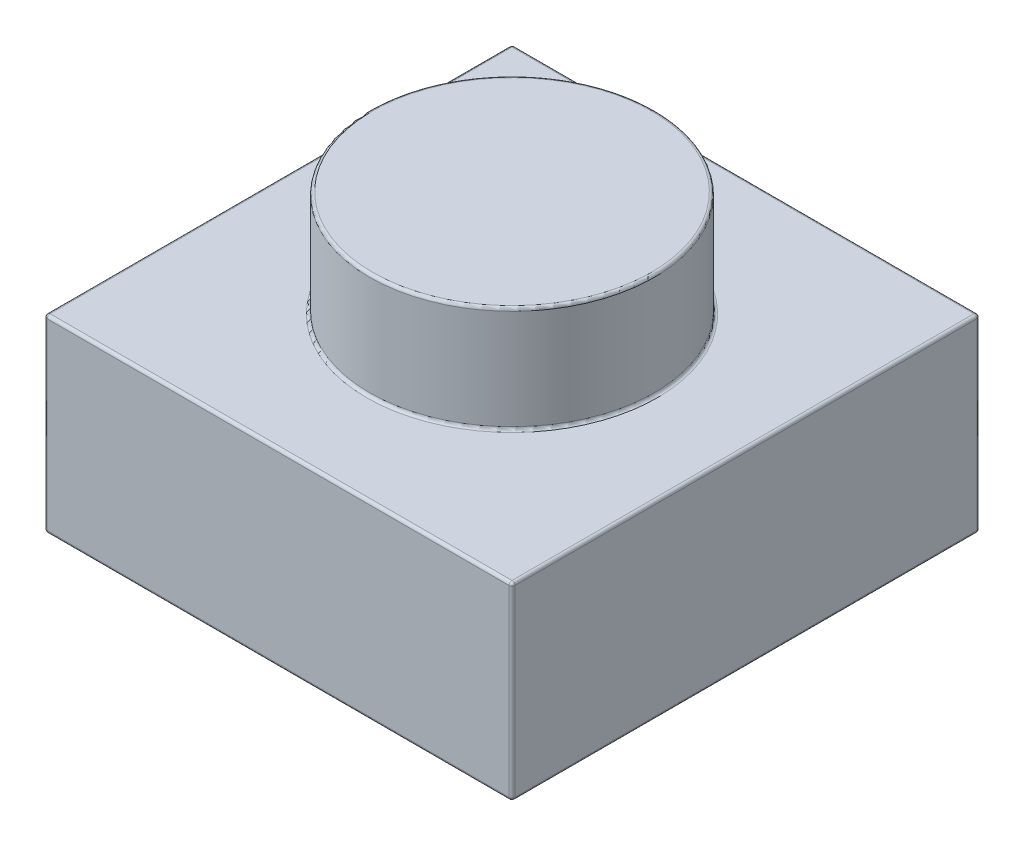
from build123d import *

# Parameters (mm, degrees)
SKETCH1_W      = 7.96
SKETCH1_H      = 7.96
EXTRUDE1_DEPTH = 3.22
SKETCH2_R      = 2.425
EXTRUDE2_DEPTH = 1.8
SHELL1_T       = -1.55
SKETCH3_W      = 4.86
SKETCH3_H      = 4.86
EXTRUDE3_DEPTH = 0.14
FILLET1_R      = 0.05


with BuildPart() as part:
    # Sketch1 → Extrude1 (new body)
    with BuildSketch(Plane(origin=(0, 0, 0), x_dir=(1, 0, 0), z_dir=(0, 1, 0))):
        Rectangle(SKETCH1_W, SKETCH1_H)
    extrude(amount=EXTRUDE1_DEPTH)

    # Sketch2 → Extrude2 (add)
    with BuildSketch(Plane(origin=(0, 3.22, 0), x_dir=(1, 0, 0), z_dir=(0, 1, 0))):
        Circle(SKETCH2_R)
    extrude(amount=EXTRUDE2_DEPTH)

    # Shell1
    shell1_openings = [part.faces().sort_by_distance(p)[0] for p in [
        (0, 0, 0),
    ]]
    offset(amount=SHELL1_T, openings=shell1_openings, kind=Kind.INTERSECTION)

    # Sketch3 → Extrude3 (cut)
    with BuildSketch(Plane.XZ.offset(-1.67)):
        Rectangle(SKETCH3_W, SKETCH3_H)
    extrude(amount=-EXTRUDE3_DEPTH, mode=Mode.SUBTRACT)

    # Fillet1
    fillet1_edges = [part.edges().sort_by_distance(p)[0] for p in [
        (-3.98, 3.22, 0),
        (0, 3.22, 3.98),
        (-2.425, 3.22, 0),
        (-2.425, 5.02, 0),
        (2.43, 0, 0),
        (2.43, 0.905, 2.43),
        (0, 0, -2.43),
        (2.43, 0.905, -2.43),
        (-2.43, 0, 0),
        (-2.43, 0.905, -2.43),
        (0, 0, 2.43),
        (-2.43, 0.905, 2.43),
        (-0.875, 3.47, 0),
        (-0.875, 1.81, 0),
        (2.43, 1.81, 0),
        (0, 1.81, -2.43),
        (-2.43, 1.81, 0),
        (0, 1.81, 2.43),
        (3.98, 3.22, 0),
        (0, 0, 3.98),
        (-3.98, 0, 0),
        (0, 0, -3.98),
        (3.98, 0, 0),
        (0, 3.22, -3.98),
        (3.98, 1.61, 3.98),
        (-3.98, 1.61, 3.98),
        (-3.98, 1.61, -3.98),
        (3.98, 1.61, -3.98),
    ]]
    fillet(fillet1_edges, radius=FILLET1_R)


solid = part.part
